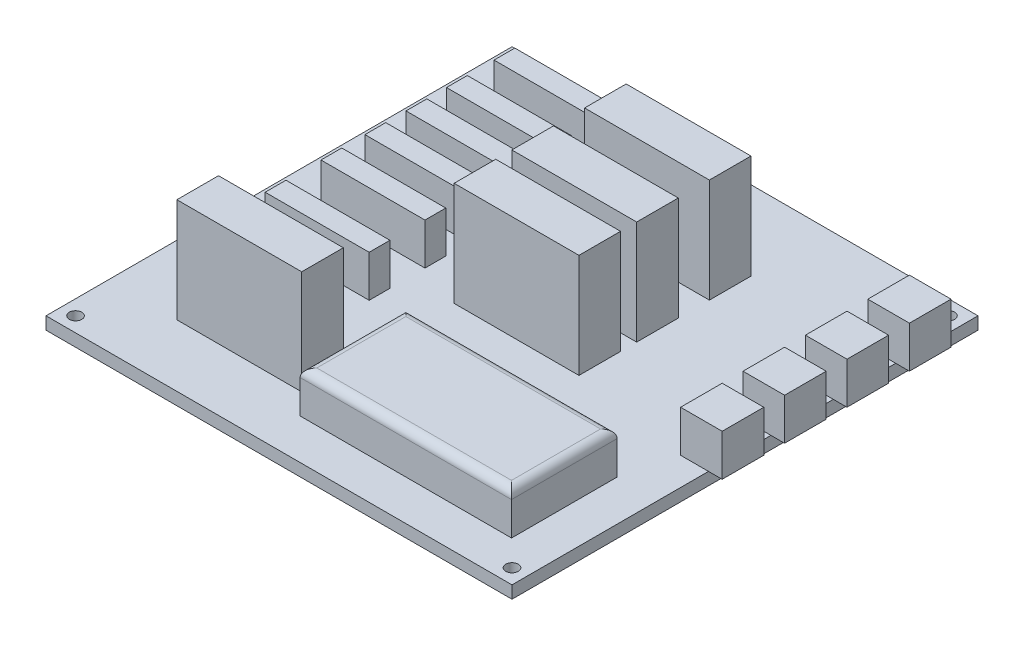
from build123d import *

# Parameters (mm, degrees)
ESQUISSE1_W      = 112
ESQUISSE1_H      = 112
ESQUISSE1_R      = 1.5
EXTRUSION1_DEPTH = 3
ESQUISSE2_W      = 50.8
ESQUISSE2_H      = 25.4
EXTRUSION2_DEPTH = 10
CONG_1_R         = 2
ESQUISSE3_W      = 10
ESQUISSE3_H      = 10
EXTRUSION3_DEPTH = 10
ESQUISSE4_W      = 30
ESQUISSE4_H      = 10
EXTRUSION4_DEPTH = 25
ESQUISSE6_W      = 25
ESQUISSE6_H      = 5
EXTRUSION6_DEPTH = 10


with BuildPart() as part:
    # Esquisse1 → Extrusion1 (new body)
    with BuildSketch(Plane(origin=(0, 0, 0), x_dir=(1, 0, 0), z_dir=(0, 1, 0))):
        with Locations((56, 56)):
            Rectangle(ESQUISSE1_W, ESQUISSE1_H)
        with Locations((3.55, 108.45)):
            Circle(ESQUISSE1_R, mode=Mode.SUBTRACT)
        with Locations((108.45, 108.45)):
            Circle(ESQUISSE1_R, mode=Mode.SUBTRACT)
        with Locations((108.45, 3.55)):
            Circle(ESQUISSE1_R, mode=Mode.SUBTRACT)
        with Locations((3.55, 3.55)):
            Circle(ESQUISSE1_R, mode=Mode.SUBTRACT)
    extrude(amount=EXTRUSION1_DEPTH)

    # Esquisse2 → Extrusion2 (add)
    with BuildSketch(Plane(origin=(0, 3, 0), x_dir=(1, 0, 0), z_dir=(0, 1, 0))):
        with Locations((76.797974596, 22.38755788)):
            Rectangle(ESQUISSE2_W, ESQUISSE2_H)
    extrude(amount=EXTRUSION2_DEPTH)

    # Congé1
    cong_1_edges = [part.edges().sort_by_distance(p)[0] for p in [
        (51.397974596, 13, -22.38755788),
        (76.797974596, 13, -9.68755788),
        (102.197974596, 13, -22.38755788),
        (76.797974596, 13, -35.08755788),
    ]]
    fillet(cong_1_edges, radius=CONG_1_R)

    # Esquisse3 → Extrusion3 (add)
    with BuildSketch(Plane(origin=(0, 3, 0), x_dir=(1, 0, 0), z_dir=(0, 1, 0))):
        with Locations((110.289997157, 97.226447648)):
            Rectangle(ESQUISSE3_W, ESQUISSE3_H)
        with Locations((110.289997157, 67.226447648)):
            Rectangle(ESQUISSE3_W, ESQUISSE3_H)
        with Locations((110.289997157, 52.226447648)):
            Rectangle(ESQUISSE3_W, ESQUISSE3_H)
        with Locations((110.289997157, 82.226447648)):
            Rectangle(ESQUISSE3_W, ESQUISSE3_H)
    extrude(amount=EXTRUSION3_DEPTH)

    # Esquisse4 → Extrusion4 (add)
    with BuildSketch(Plane(origin=(0, 3, 0), x_dir=(1, 0, 0), z_dir=(0, 1, 0))):
        with Locations((61.461032567, 56.630717004)):
            Rectangle(ESQUISSE4_W, ESQUISSE4_H)
        with Locations((61.461032567, 70.501921666)):
            Rectangle(ESQUISSE4_W, ESQUISSE4_H)
        with Locations((31.569885157, 19.889690111)):
            Rectangle(ESQUISSE4_W, ESQUISSE4_H)
        with Locations((61.461032567, 87.97905365)):
            Rectangle(ESQUISSE4_W, ESQUISSE4_H)
    extrude(amount=EXTRUSION4_DEPTH)

    # Esquisse6 → Extrusion6 (add)
    with BuildSketch(Plane(origin=(0, 3, 0), x_dir=(1, 0, 0), z_dir=(0, 1, 0))):
        with Locations((23.111824989, 78.410936793)):
            Rectangle(ESQUISSE6_W, ESQUISSE6_H)
        with Locations((23.111824989, 57.971644922)):
            Rectangle(ESQUISSE6_W, ESQUISSE6_H)
        with Locations((23.111824989, 68.536691251)):
            Rectangle(ESQUISSE6_W, ESQUISSE6_H)
        with Locations((23.111824989, 44.556380649)):
            Rectangle(ESQUISSE6_W, ESQUISSE6_H)
        with Locations((23.111824989, 88.144121685)):
            Rectangle(ESQUISSE6_W, ESQUISSE6_H)
        with Locations((23.111824989, 99.570034384)):
            Rectangle(ESQUISSE6_W, ESQUISSE6_H)
    extrude(amount=EXTRUSION6_DEPTH)


solid = part.part
